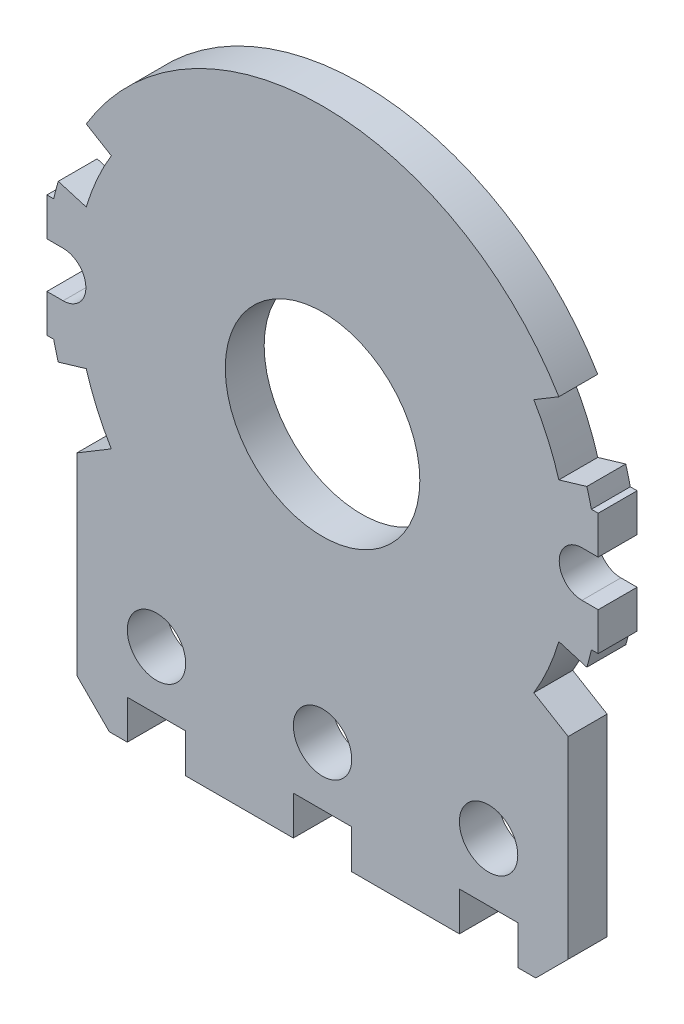
from build123d import *

# Parameters (mm, degrees)
SKETCH1_R           = 3
BOSS_EXTRUDE1_DEPTH = 1.2
SKETCH2_R           = 0.9
SKETCH2_W           = 1.8
SKETCH2_H           = 1.2
CUT_EXTRUDE1_DEPTH  = 2.2
SKETCH3_R           = 0.701713619
SKETCH3_W           = 1
SKETCH3_H           = 1.403427238
CUT_EXTRUDE2_DEPTH  = 10


with BuildPart() as part:
    # Sketch1 → Boss-Extrude1 (new body)
    with BuildSketch(Plane.XY):
        with BuildLine():
            Line((-7.575, -3.856082857), (-7.575, -11.5))
            Line((-7.575, -11.5), (7.575, -11.5))
            Line((7.575, -11.5), (7.575, -3.856082857))
            ThreePointArc((7.575, -3.856082857), (7.994413326, -2.887794239), (8.290619699, -1.875))
            Line((8.290619699, -1.875), (8.5, -1.875))
            Line((8.5, -1.875), (8.5, 1.875))
            Line((8.5, 1.875), (8.290619699, 1.875))
            ThreePointArc((8.290619699, 1.875), (0, 8.5), (-8.290619699, 1.875))
            Line((-8.290619699, 1.875), (-8.5, 1.875))
            Line((-8.5, 1.875), (-8.5, -1.875))
            Line((-8.5, -1.875), (-8.290619699, -1.875))
            ThreePointArc((-8.290619699, -1.875), (-7.994413326, -2.887794239), (-7.575, -3.856082857))
        make_face()
        Circle(SKETCH1_R, mode=Mode.SUBTRACT)
    extrude(amount=BOSS_EXTRUDE1_DEPTH)

    # Sketch2 → Cut-Extrude1 (cut, through all)
    with BuildSketch(Plane.XY.offset(1.2)):
        with Locations((0, -8.5)):
            Circle(SKETCH2_R)
        with Locations((5.12, -8.5)):
            Circle(SKETCH2_R)
        with Locations((-5.12, -8.5)):
            Circle(SKETCH2_R)
        with Locations((5.12, -10.9)):
            Rectangle(SKETCH2_W, SKETCH2_H)
        with Locations((0, -10.9)):
            Rectangle(SKETCH2_W, SKETCH2_H)
        with Locations((-5.12, -10.9)):
            Rectangle(SKETCH2_W, SKETCH2_H)
        Polygon((7.575, -11.5), (7.575, -10.5), (6.575, -11.5), align=None)
        Polygon((-6.575, -11.5), (-7.575, -11.5), (-7.575, -10.5), align=None)
    extrude(amount=-CUT_EXTRUDE1_DEPTH, mode=Mode.SUBTRACT)

    # Sketch3 → Cut-Extrude2 (cut)
    with BuildSketch(Plane.XY.offset(1.2)):
        with Locations((8, 0)):
            Circle(SKETCH3_R)
        with Locations((-8, 0)):
            Circle(SKETCH3_R)
        with BuildLine():
            Line((7.287029985, 2.15851662), (9.119724122, 2.701385355))
            Line((9.119724122, 2.701385355), (8.018790887, 4.818175656))
            Line((8.018790887, 4.818175656), (6.514471485, 3.914289369))
            ThreePointArc((6.514471485, 3.914289369), (6.956367241, 3.060874843), (7.287029985, 2.15851662))
        make_face()
        with BuildLine():
            Line((8.018790887, -4.818175656), (9.119724122, -2.701385355))
            Line((9.119724122, -2.701385355), (7.287029985, -2.15851662))
            ThreePointArc((7.287029985, -2.15851662), (6.956367241, -3.060874843), (6.514471485, -3.914289369))
            Line((6.514471485, -3.914289369), (8.018790887, -4.818175656))
        make_face()
        with BuildLine():
            Line((-7.287029985, -2.15851662), (-9.119724122, -2.701385355))
            Line((-9.119724122, -2.701385355), (-8.018790887, -4.818175656))
            Line((-8.018790887, -4.818175656), (-6.514471485, -3.914289369))
            ThreePointArc((-6.514471485, -3.914289369), (-6.956367241, -3.060874843), (-7.287029985, -2.15851662))
        make_face()
        with BuildLine():
            Line((-8.018790887, 4.818175656), (-9.119724122, 2.701385355))
            Line((-9.119724122, 2.701385355), (-7.287029985, 2.15851662))
            ThreePointArc((-7.287029985, 2.15851662), (-6.956367241, 3.060874843), (-6.514471485, 3.914289369))
            Line((-6.514471485, 3.914289369), (-8.018790887, 4.818175656))
        make_face()
        with Locations((-8.5, 0)):
            Rectangle(SKETCH3_W, SKETCH3_H)
        with Locations((8.5, 0)):
            Rectangle(SKETCH3_W, SKETCH3_H)
    extrude(amount=-CUT_EXTRUDE2_DEPTH, mode=Mode.SUBTRACT)


solid = part.part
